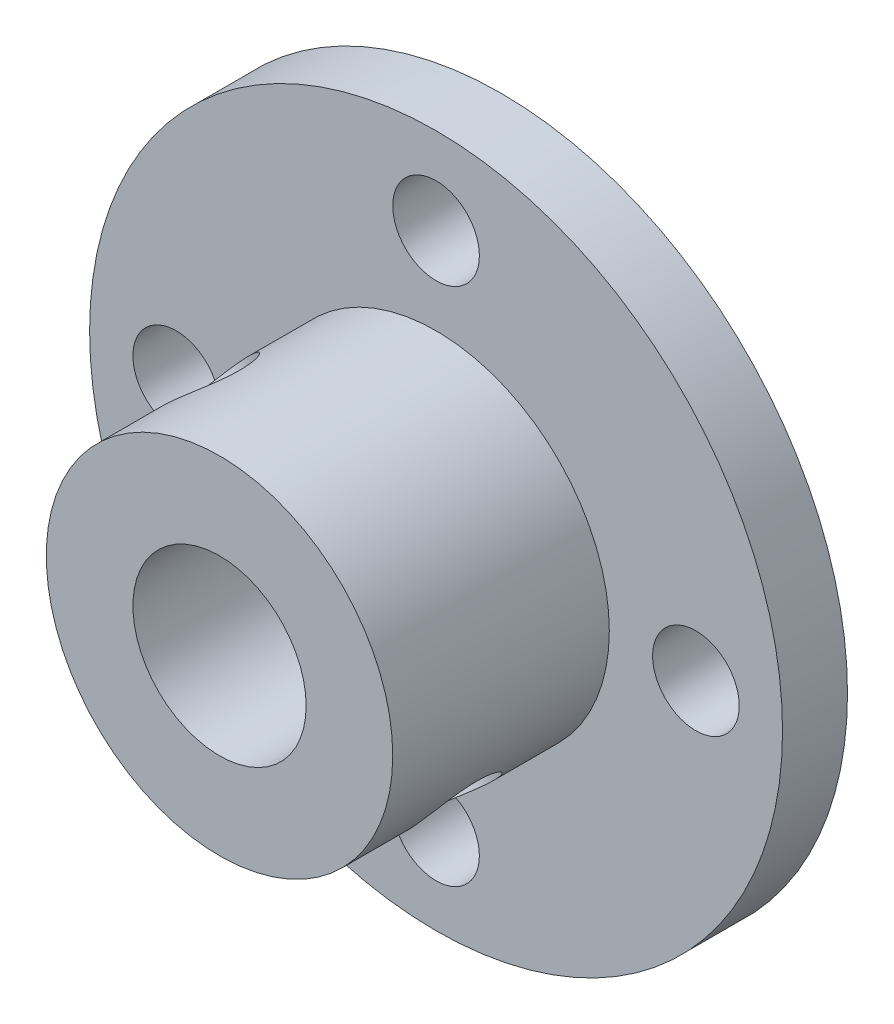
from build123d import *

# Parameters (mm, degrees)
SKETCH1_R           = 16
BOSS_EXTRUDE1_DEPTH = 3
SKETCH3_R           = 8
BOSS_EXTRUDE2_DEPTH = 10
CUT_EXTRUDE1_REACH  = 5
SKETCH2_R           = 2
CUT_EXTRUDE2_REACH  = 32.627
SKETCH5_R           = 2
SKETCH6_R           = 4
CUT_EXTRUDE3_DEPTH  = 13


with BuildPart() as part:
    # Sketch1 → Boss-Extrude1 (new body)
    with BuildSketch(Plane.XY):
        Circle(SKETCH1_R)
    extrude(amount=BOSS_EXTRUDE1_DEPTH)

    # Sketch3 → Boss-Extrude2 (add)
    with BuildSketch(Plane.XY.offset(3)):
        Circle(SKETCH3_R)
    extrude(amount=BOSS_EXTRUDE2_DEPTH)

    # Sketch2 → Cut-Extrude1 (cut, up to next)
    with BuildSketch(Plane.XY.offset(3), mode=Mode.PRIVATE) as cut_extrude1_sk1:
        with Locations((0, 12)):
            Circle(SKETCH2_R)
    cut_extrude1_tool1 = extrude(cut_extrude1_sk1.sketch, amount=-CUT_EXTRUDE1_REACH, mode=Mode.PRIVATE) & part.part
    add(cut_extrude1_tool1.solids().sort_by_distance((0, 12, 3))[0], mode=Mode.SUBTRACT)
    # Sketch2 → Cut-Extrude1 (cut, up to next)
    with BuildSketch(Plane.XY.offset(3), mode=Mode.PRIVATE) as cut_extrude1_sk2:
        with Locations((12, 0)):
            Circle(SKETCH2_R)
    cut_extrude1_tool2 = extrude(cut_extrude1_sk2.sketch, amount=-CUT_EXTRUDE1_REACH, mode=Mode.PRIVATE) & part.part
    add(cut_extrude1_tool2.solids().sort_by_distance((12, 0, 3))[0], mode=Mode.SUBTRACT)
    # Sketch2 → Cut-Extrude1 (cut, up to next)
    with BuildSketch(Plane.XY.offset(3), mode=Mode.PRIVATE) as cut_extrude1_sk3:
        with Locations((0, -12)):
            Circle(SKETCH2_R)
    cut_extrude1_tool3 = extrude(cut_extrude1_sk3.sketch, amount=-CUT_EXTRUDE1_REACH, mode=Mode.PRIVATE) & part.part
    add(cut_extrude1_tool3.solids().sort_by_distance((0, -12, 3))[0], mode=Mode.SUBTRACT)
    # Sketch2 → Cut-Extrude1 (cut, up to next)
    with BuildSketch(Plane.XY.offset(3), mode=Mode.PRIVATE) as cut_extrude1_sk4:
        with Locations((-12, 0)):
            Circle(SKETCH2_R)
    cut_extrude1_tool4 = extrude(cut_extrude1_sk4.sketch, amount=-CUT_EXTRUDE1_REACH, mode=Mode.PRIVATE) & part.part
    add(cut_extrude1_tool4.solids().sort_by_distance((-12, 0, 3))[0], mode=Mode.SUBTRACT)

    # Sketch5 → Cut-Extrude2 (cut, up to next)
    with BuildSketch(Plane(origin=(5.656854249, -5.656854249, 0), x_dir=(-0.707106781, -0.707106781, 0), z_dir=(0.707106781, -0.707106781, 0)), mode=Mode.PRIVATE) as cut_extrude2_sk1:
        with Locations((0, -8)):
            Circle(SKETCH5_R)
    cut_extrude2_tool1 = extrude(cut_extrude2_sk1.sketch, amount=-CUT_EXTRUDE2_REACH, mode=Mode.PRIVATE) & part.part
    add(cut_extrude2_tool1.solids().sort_by_distance((5.656854, -5.656854, 8))[0], mode=Mode.SUBTRACT)

    # Sketch6 → Cut-Extrude3 (cut)
    with BuildSketch(Plane.XY.offset(13)):
        Circle(SKETCH6_R)
    extrude(amount=-CUT_EXTRUDE3_DEPTH, mode=Mode.SUBTRACT)


solid = part.part
